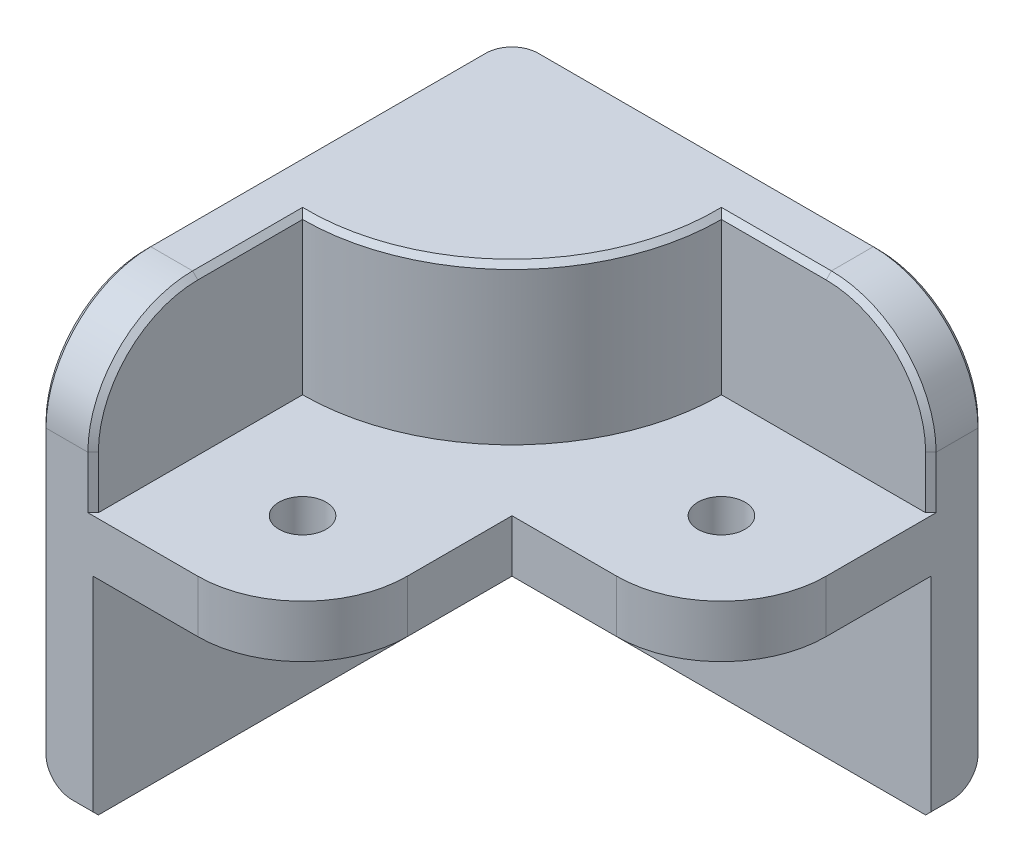
from build123d import *

# Parameters (mm, degrees)
BOSS_EXTRUDE1_DEPTH  = 40
BOSS_EXTRUDE2_START  = -20
BOSS_EXTRUDE2_DEPTH  = 5
FILLET1_R            = 10
FILLET2_R            = 3
M4_CLEARANCE_HOLE1_D = 4.5
BOSS_EXTRUDE3_REACH  = 42
CHAMFER1_SIZE        = 0.5


with BuildPart() as part:
    # Sketch1 → Boss-Extrude1 (new body)
    with BuildSketch(Plane(origin=(0, 0, 0), x_dir=(1, 0, 0), z_dir=(0, 1, 0))):
        Polygon((0, 0), (0, -45), (5, -45), (5, -5), (45, -5), (45, 0), align=None)
    extrude(amount=-BOSS_EXTRUDE1_DEPTH)

    # Sketch2 → Boss-Extrude2 (add)
    with BuildSketch(Plane.XZ.offset(40).offset(BOSS_EXTRUDE2_START)):
        Polygon((5, 45), (25, 45), (25, 25), (45, 25), (45, 5), (5, 5), align=None)
    extrude(amount=-BOSS_EXTRUDE2_DEPTH)

    # Fillet1
    fillet1_edges = [part.edges().sort_by_distance(p)[0] for p in [
        (25, -17.5, 45),
        (45, -17.5, 25),
        (45, 0, 2.5),
        (2.5, 0, 45),
    ]]
    fillet(fillet1_edges, radius=FILLET1_R)

    # Fillet2
    fillet2_edges = [part.edges().sort_by_distance(p)[0] for p in [
        (0, -20, 0),
        (22.5, -40, 0),
        (0, -40, 22.5),
    ]]
    fillet(fillet2_edges, radius=FILLET2_R)

    # M4 Clearance Hole1 (through all)
    with Locations(Plane(origin=(0, -15, 0), x_dir=(1, 0, 0), z_dir=(0, 1, 0))):
        with Locations((35, -15), (15, -35)):
            Hole(M4_CLEARANCE_HOLE1_D / 2)

    # Sketch5 → Boss-Extrude3 (add, up to next)
    with BuildSketch(Plane(origin=(0, 0, 0), x_dir=(1, 0, 0), z_dir=(0, 1, 0)), mode=Mode.PRIVATE) as boss_extrude3_sk1:
        with BuildLine():
            Line((5, -25), (5, -5))
            Line((5, -5), (25, -5))
            ThreePointArc((25, -5), (19.142135624, -19.142135624), (5, -25))
        make_face()
    boss_extrude3_tool1 = extrude(boss_extrude3_sk1.sketch, amount=-BOSS_EXTRUDE3_REACH, mode=Mode.PRIVATE) - part.part
    add(boss_extrude3_tool1.solids().sort_by_distance((13.488264, 0, 13.488264))[0])

    # Chamfer1
    chamfer1_edges = [part.edges().sort_by_distance(p)[0] for p in [
        (4, -40, 45),
        (45, -40, 4),
        (0.878679656, -39.121320344, 45),
        (45, -39.121320344, 0.878679656),
        (0, -23.5, 45),
        (45, -23.5, 0),
        (0, -2.928932188, 42.071067812),
        (42.071067812, -2.928932188, 0),
        (0, 0, 19),
        (0.878679656, 0, 0.878679656),
        (19, 0, 0),
        (5, -12.5, 45),
        (45, -12.5, 5),
        (5, -2.928932188, 42.071067812),
        (42.071067812, -2.928932188, 5),
        (5, 0, 30),
        (30, 0, 5),
        (19.142135624, 0, 19.142135624),
    ]]
    chamfer(chamfer1_edges, length=CHAMFER1_SIZE)


solid = part.part
